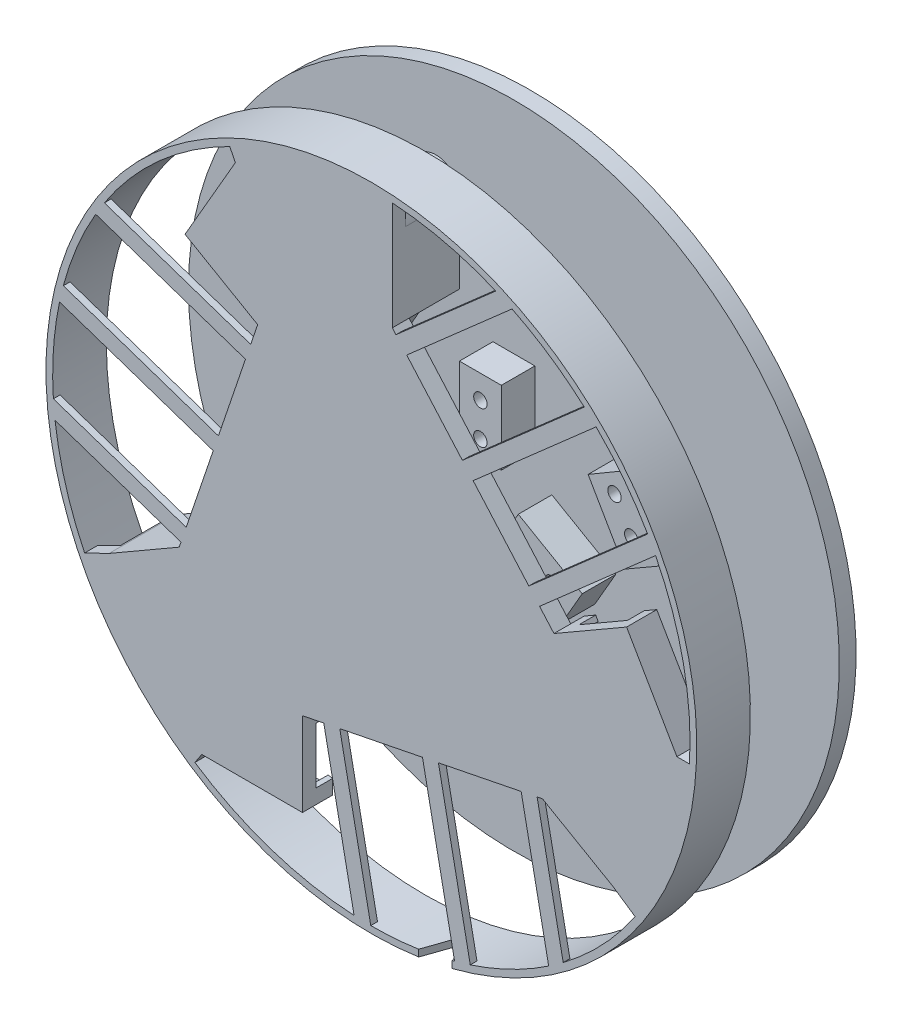
from build123d import *

# Parameters (mm, degrees)
CROQUIS1_R                  = 9.313545519
SALIENTE_EXTRUIR2_DEPTH     = 20
CROQUIS1_R_2                = 2
SALIENTE_EXTRUIR2_2_DEPTH   = 20
SALIENTE_EXTRUIR2_3_DEPTH   = 20
SALIENTE_EXTRUIR2_4_DEPTH   = 20
CROQUIS2_R                  = 97
SALIENTE_EXTRUIR3_DEPTH     = 4
CROQUIS3_R                  = 2
CORTAR_EXTRUIR2_DEPTH       = 36
SALIENTE_EXTRUIR6_DEPTH     = 5
CROQUIS6_R                  = 97
CROQUIS6_R_2                = 95
SALIENTE_EXTRUIR7_DEPTH     = 35
CROQUIS7_W                  = 36.537467555
CROQUIS7_H                  = 51.413436488
CORTAR_EXTRUIR6_DEPTH       = 40
SALIENTE_EXTRUIR13_DEPTH    = 3
CROQUIS12_W                 = 10
CROQUIS12_H                 = 16.770096614
CORTAR_EXTRUIR7_DEPTH       = 10
CORTAR_EXTRUIR7_TAPER       = 24
SALIENTE_EXTRUIR20_DEPTH    = 2
SALIENTE_EXTRUIR22_DEPTH    = 2
CROQUIS21_R                 = 2
SALIENTE_EXTRUIR23_DEPTH    = 12.5
CROQUIS26_R                 = 2
SALIENTE_EXTRUIR25_DEPTH    = 10
CROQUIS29_R                 = 97
SALIENTE_EXTRUIR26_DEPTH    = 5
CROQUIS32_R                 = 97
CROQUIS32_R_2               = 95
CORTAR_EXTRUIR9_DEPTH       = 23
SALIENTE_EXTRUIR28_DEPTH    = 1
CROQUIS38_W                 = 12.5
CROQUIS38_H                 = 24.157813479
CROQUIS38_H_2               = 22.825822027
CROQUIS38_H_3               = 74.173968243
CORTAR_EXTRUIR17_DEPTH      = 202
CORTAR_EXTRUIR17_DEPTH_BACK = 299


with BuildPart() as part:
    # Croquis1 → Saliente-Extruir2 (new body)
    with BuildSketch(Plane.XY):
        with Locations((-174.594182716, 121.255426097)):
            Circle(CROQUIS1_R)
    extrude(amount=SALIENTE_EXTRUIR2_DEPTH)

    # Croquis7 → Cortar-Extruir6 (cut, through all)
    with BuildSketch(Plane.XY.offset(20)):
        with Locations((-172.983924952, 117.945017294)):
            Rectangle(CROQUIS7_W, CROQUIS7_H)
    extrude(amount=-CORTAR_EXTRUIR6_DEPTH, mode=Mode.SUBTRACT)


with BuildPart() as body_2:
    # Croquis1 → Saliente-Extruir2 2 (new body)
    with BuildSketch(Plane.XY):
        with BuildLine():
            Line((-250.851688073, 84.445013217), (-252.79514461, 83.322958062))
            ThreePointArc((-252.79514461, 83.322958062), (-256.056625394, 75.449046919), (-249.29514461, 70.260780235))
            Line((-249.29514461, 70.260780235), (-247.137331132, 70.260780235))
            Line((-247.137331132, 70.260780235), (-225.137331132, 70.260780235))
            Line((-225.137331132, 70.260780235), (-225.137331132, 82.760780235))
            Line((-225.137331132, 82.760780235), (-228.768865169, 82.760780235))
            Line((-228.768865169, 82.760780235), (-225.623864438, 84.576547254))
            Line((-225.623864438, 84.576547254), (-231.873864438, 95.401864801))
            Line((-231.873864438, 95.401864801), (-244.676423321, 88.010303983))
            Line((-244.676423321, 88.010303983), (-250.851688073, 84.445013217))
        make_face()
        with Locations((-234.811042265, 86.489206027)):
            Circle(CROQUIS1_R_2, mode=Mode.SUBTRACT)
        with Locations((-243.471296302, 81.489206027)):
            Circle(CROQUIS1_R_2, mode=Mode.SUBTRACT)
        with Locations((-232.137331132, 76.510780235)):
            Circle(CROQUIS1_R_2, mode=Mode.SUBTRACT)
        with Locations((-242.137331132, 76.510780235)):
            Circle(CROQUIS1_R_2, mode=Mode.SUBTRACT)
    extrude(amount=SALIENTE_EXTRUIR2_2_DEPTH)



with BuildPart() as body_3:
    # Croquis1 → Saliente-Extruir2 3 (new body)
    with BuildSketch(Plane.XY):
        with BuildLine():
            Line((-180.844182716, 187.419400274), (-180.844182716, 183.787866237))
            Line((-180.844182716, 183.787866237), (-168.344182716, 183.787866237))
            Line((-168.344182716, 183.787866237), (-168.344182716, 198.570987873))
            Line((-168.344182716, 198.570987873), (-168.344182716, 205.701569406))
            Line((-168.344182716, 205.701569406), (-168.344182716, 207.945679716))
            ThreePointArc((-168.344182716, 207.945679716), (-173.5324494, 214.7071605), (-181.406360543, 211.445679716))
            Line((-181.406360543, 211.445679716), (-182.485267282, 209.576958427))
            Line((-182.485267282, 209.576958427), (-193.485267282, 190.524399544))
            Line((-193.485267282, 190.524399544), (-182.659949735, 184.274399544))
            Line((-182.659949735, 184.274399544), (-180.844182716, 187.419400274))
        make_face()
        with Locations((-179.572608508, 202.121831408)):
            Circle(CROQUIS1_R_2, mode=Mode.SUBTRACT)
        with Locations((-174.594182716, 190.787866237)):
            Circle(CROQUIS1_R_2, mode=Mode.SUBTRACT)
        with Locations((-184.572608508, 193.46157737)):
            Circle(CROQUIS1_R_2, mode=Mode.SUBTRACT)
        with Locations((-174.594182716, 200.787866237)):
            Circle(CROQUIS1_R_2, mode=Mode.SUBTRACT)
    extrude(amount=SALIENTE_EXTRUIR2_3_DEPTH)


with BuildPart() as body_4:
    # Croquis1 → Saliente-Extruir2 4 (new body)
    with BuildSketch(Plane.XY):
        with BuildLine():
            Line((-123.564500994, 84.576547254), (-110.761942111, 77.184986436))
            Line((-110.761942111, 77.184986436), (-104.586677359, 73.619695669))
            Line((-104.586677359, 73.619695669), (-102.643220822, 72.497640514))
            ThreePointArc((-102.643220822, 72.497640514), (-94.193473354, 73.610070873), (-93.081042995, 82.059818341))
            Line((-93.081042995, 82.059818341), (-94.159949735, 83.92853963))
            Line((-94.159949735, 83.92853963), (-105.159949735, 102.981098513))
            Line((-105.159949735, 102.981098513), (-115.985267282, 96.731098513))
            Line((-115.985267282, 96.731098513), (-114.169500263, 93.586097782))
            Line((-114.169500263, 93.586097782), (-117.314500994, 95.401864801))
            Line((-117.314500994, 95.401864801), (-123.564500994, 84.576547254))
        make_face()
        with Locations((-102.072608508, 85.133666649)):
            Circle(CROQUIS1_R_2, mode=Mode.SUBTRACT)
        with Locations((-107.072608508, 93.793920687)):
            Circle(CROQUIS1_R_2, mode=Mode.SUBTRACT)
        with Locations((-105.71706913, 81.489206027)):
            Circle(CROQUIS1_R_2, mode=Mode.SUBTRACT)
        with Locations((-114.377323168, 86.489206027)):
            Circle(CROQUIS1_R_2, mode=Mode.SUBTRACT)
    extrude(amount=SALIENTE_EXTRUIR2_4_DEPTH)


with BuildPart() as body_2_1:
    add(body_2.part)

    add(body_3.part)  # Saliente-Extruir3 merges body 3

    add(body_4.part)  # Saliente-Extruir3 merges body 4
    # Croquis2 → Saliente-Extruir3 (add)
    with BuildSketch(Plane.XY.offset(20)):
        with Locations((-174.594182716, 121.255426097)):
            Circle(CROQUIS2_R)
        with BuildLine():
            Line((-105.159949735, 102.981098513), (-120.159949735, 128.961860627))
            Line((-120.159949735, 128.961860627), (-98.50931464, 141.461860627))
            Line((-98.50931464, 141.461860627), (-83.50931464, 115.481098513))
            Line((-83.50931464, 115.481098513), (-79.769833834, 115.481098513))
            ThreePointArc((-79.769833834, 115.481098513), (-103.302441057, 184.044657429), (-168.344182716, 216.049611046))
            Line((-168.344182716, 216.049611046), (-168.344182716, 207.945679716))
            Line((-168.344182716, 207.945679716), (-168.344182716, 183.787866237))
            Line((-168.344182716, 183.787866237), (-180.844182716, 183.787866237))
            Line((-180.844182716, 183.787866237), (-180.844182716, 187.419400274))
            Line((-180.844182716, 187.419400274), (-182.659949735, 184.274399544))
            Line((-182.659949735, 184.274399544), (-193.485267282, 190.524399544))
            Line((-193.485267282, 190.524399544), (-208.485267282, 164.54363743))
            Line((-208.485267282, 164.54363743), (-230.135902377, 177.04363743))
            Line((-230.135902377, 177.04363743), (-217.348968797, 199.191256063))
            Line((-217.348968797, 199.191256063), (-215.135902377, 203.024399544))
            Line((-215.135902377, 203.024399544), (-216.793807303, 206.368243491))
            ThreePointArc((-216.793807303, 206.368243491), (-264.48542547, 151.989193784), (-260.069291522, 79.794531575))
            Line((-260.069291522, 79.794531575), (-252.79514461, 83.322958062))
            Line((-252.79514461, 83.322958062), (-249.29514461, 70.260780235))
            Line((-249.29514461, 70.260780235), (-225.137331132, 70.260780235))
            Line((-225.137331132, 70.260780235), (-195.137331132, 70.260780235))
            Line((-195.137331132, 70.260780235), (-195.137331132, 45.260780235))
            Line((-195.137331132, 45.260780235), (-225.137331132, 45.260780235))
            Line((-225.137331132, 45.260780235), (-227.204232473, 42.153070478))
            ThreePointArc((-227.204232473, 42.153070478), (-156.26478491, 28.040442452), (-95.950440393, 67.962257741))
            Line((-95.950440393, 67.962257741), (-102.643220822, 72.497640514))
            Line((-102.643220822, 72.497640514), (-94.499038829, 84.515859169))
            Line((-94.499038829, 84.515859169), (-105.159949735, 102.981098513))
        make_face(mode=Mode.SUBTRACT)
    extrude(amount=-SALIENTE_EXTRUIR3_DEPTH)

    # Croquis3 → Cortar-Extruir2 (cut)
    with BuildSketch(Plane(origin=(0, 0, 0), x_dir=(-1, 0, 0), z_dir=(0, 0, -1))):
        with Locations((174.594182716, 200.787866237)):
            Circle(CROQUIS3_R)
        with Locations((179.572608508, 202.121831408)):
            Circle(CROQUIS3_R)
        with Locations((184.572608508, 193.46157737)):
            Circle(CROQUIS3_R)
        with Locations((174.594182716, 190.787866237)):
            Circle(CROQUIS3_R)
    extrude(amount=-CORTAR_EXTRUIR2_DEPTH, mode=Mode.SUBTRACT)

    # Croquis5 → Saliente-Extruir6 (add)
    with BuildSketch(Plane(origin=(0, 0, 16), x_dir=(-1, 0, 0), z_dir=(0, 0, -1))):
        Polygon((195.137331132, 70.260780235), (195.137331132, 66.284420348), (196.629622791, 66.284420348), (196.629622791, 68.733603213), (241.76303174, 68.733603213), (241.76303174, 70.260780235), (225.137331132, 70.260780235), align=None)
        Polygon((120.159949735, 128.961860627), (116.716321058, 130.95004057), (115.970175228, 129.657678083), (118.091229808, 128.433086651), (95.524525333, 89.346407942), (96.847099431, 88.582819431), (105.159949735, 102.981098513), align=None)
        Polygon((208.485267282, 164.54363743), (211.928895959, 166.531817374), (211.182750129, 167.824179861), (209.06169555, 166.599588428), (186.494991075, 205.686267137), (185.172416978, 204.922678626), (193.485267282, 190.524399544), align=None)
        Polygon((230.135902377, 177.04363743), (215.135902377, 203.024399544), (213.023103549, 202.793743883), (226.723342516, 179.013879784), (227.75030659, 177.231351308), (225.551355532, 175.964474641), (226.394943709, 174.883793937), align=None)
        Polygon((198.549890992, 47.231022589), (225.993976884, 47.205845524), (225.137331132, 45.260780235), (195.137331132, 45.260780235), (195.137331132, 49.580467222), (196.495022164, 49.770695662), (196.492694012, 47.232909851), align=None)
        Polygon((83.50931464, 115.481098513), (98.50931464, 141.461860627), (102.250273307, 139.302017133), (101.736170452, 138.031107989), (99.539547547, 139.302017133), (98.50931464, 137.521375919), (84.765467716, 113.766688886), align=None)
    extrude(amount=SALIENTE_EXTRUIR6_DEPTH)

    # Croquis6 → Saliente-Extruir7 (add)
    with BuildSketch(Plane(origin=(0, 0, 16), x_dir=(-1, 0, 0), z_dir=(0, 0, -1))):
        with Locations((174.594182716, 121.255426097)):
            Circle(CROQUIS6_R)
        with Locations((174.594182716, 121.255426097)):
            Circle(CROQUIS6_R_2, mode=Mode.SUBTRACT)
    extrude(amount=SALIENTE_EXTRUIR7_DEPTH)

    # Croquis9 → Saliente-Extruir13 (add)
    with BuildSketch(Plane.XY.offset(20)):
        Polygon((-195.137331132, 70.260780235), (-123.564500994, 84.576547254), (-117.314500994, 95.401864801), (-114.169500263, 93.586097782), (-115.985267282, 96.731098513), (-105.159949735, 102.981098513), (-120.159949735, 128.961860627), (-168.344182716, 183.787866237), (-180.844182716, 183.787866237), (-180.844182716, 187.419400274), (-182.659949735, 184.274399544), (-193.485267282, 190.524399544), (-208.485267282, 164.54363743), (-231.873864438, 95.401864801), (-225.623864438, 84.576547254), (-228.768865169, 82.760780235), (-225.137331132, 82.760780235), (-225.137331132, 70.260780235), align=None)
    extrude(amount=-SALIENTE_EXTRUIR13_DEPTH)

    # Croquis12 → Cortar-Extruir7 (cut)
    with BuildSketch(Plane.XY.offset(20)):
        with Locations((-155.482716106, 26.156783394)):
            Rectangle(CROQUIS12_W, CROQUIS12_H)
    extrude(amount=-CORTAR_EXTRUIR7_DEPTH, taper=CORTAR_EXTRUIR7_TAPER, mode=Mode.SUBTRACT)

    # Croquis13 → Saliente-Extruir20 (add)
    with BuildSketch(Plane.XY.offset(20)):
        with BuildLine():
            Line((-256.780786671, 168.903743281), (-212.120681578, 153.796563247))
            Line((-212.120681578, 153.796563247), (-210.566560891, 158.390881516))
            Line((-210.566560891, 158.390881516), (-254.173169225, 173.141695053))
            ThreePointArc((-254.173169225, 173.141695053), (-255.504729762, 171.039794896), (-256.780786671, 168.903743281))
        make_face()
        with BuildLine():
            Line((-267.546087574, 140.875400188), (-221.733686547, 125.378432847))
            Line((-221.733686547, 125.378432847), (-220.17956586, 129.972751116))
            Line((-220.17956586, 129.972751116), (-266.418272853, 145.613925036))
            ThreePointArc((-266.418272853, 145.613925036), (-267.012554732, 143.251892041), (-267.546087574, 140.875400188))
        make_face()
        with BuildLine():
            Line((-231.346691517, 96.960302446), (-229.792570829, 101.554620715))
            Line((-229.792570829, 101.554620715), (-269.38452378, 114.947396211))
            ThreePointArc((-269.38452378, 114.947396211), (-269.171057581, 112.299157855), (-268.883619856, 109.657924477))
            Line((-268.883619856, 109.657924477), (-231.346691517, 96.960302446))
        make_face()
        with BuildLine():
            Line((-111.126834303, 191.944149989), (-147.453802216, 160.017930562))
            Line((-147.453802216, 160.017930562), (-144.252066225, 156.374863432))
            Line((-144.252066225, 156.374863432), (-107.587058769, 188.598171366))
            ThreePointArc((-107.587058769, 188.598171366), (-109.335498408, 190.293851067), (-111.126834303, 191.944149989))
        make_face()
        with BuildLine():
            Line((-167.258122586, 182.552102273), (-164.056386596, 178.909035142))
            Line((-164.056386596, 178.909035142), (-132.661926314, 206.500284435))
            ThreePointArc((-132.661926314, 206.500284435), (-135.062101104, 207.639536462), (-137.49319517, 208.711224779))
            Line((-137.49319517, 208.711224779), (-167.258122586, 182.552102273))
        make_face()
        with BuildLine():
            Line((-92.23622761, 168.606954381), (-127.649481846, 137.483758852))
            Line((-127.649481846, 137.483758852), (-124.447745855, 133.840691722))
            Line((-124.447745855, 133.840691722), (-89.869862438, 164.229715544))
            ThreePointArc((-89.869862438, 164.229715544), (-91.024381102, 166.433830874), (-92.23622761, 168.606954381))
        make_face()
        with BuildLine():
            Line((-145.109626271, 30.946728115), (-154.595059385, 78.369914883))
            Line((-154.595059385, 78.369914883), (-159.350916063, 77.418663744))
            Line((-159.350916063, 77.418663744), (-149.777216527, 29.55418189))
            ThreePointArc((-149.777216527, 29.55418189), (-147.434495009, 30.220535184), (-145.109626271, 30.946728115))
        make_face()
        with BuildLine():
            Line((-174.765533867, 26.25558063), (-184.012384725, 72.485956193))
            Line((-184.012384725, 72.485956193), (-188.768241403, 71.534705054))
            Line((-188.768241403, 71.534705054), (-179.739516485, 26.394867695))
            ThreePointArc((-179.739516485, 26.394867695), (-177.253437284, 26.292652522), (-174.765533867, 26.25558063))
        make_face()
        with BuildLine():
            Line((-125.177734046, 84.253873573), (-129.933590723, 83.302622435))
            Line((-129.933590723, 83.302622435), (-121.736098055, 42.318597646))
            ThreePointArc((-121.736098055, 42.318597646), (-119.549389463, 43.827583975), (-117.405733123, 45.397129036))
            Line((-117.405733123, 45.397129036), (-125.177734046, 84.253873573))
        make_face()
    extrude(amount=-SALIENTE_EXTRUIR20_DEPTH)

    # Croquis14 → Saliente-Extruir22 (add)
    with BuildSketch(Plane(origin=(0, 0, 17), x_dir=(-1, 0, 0), z_dir=(0, 0, -1))):
        Polygon((193.485267282, 190.524399544), (182.659949735, 184.274399544), (180.844182716, 187.419400274), (180.844182716, 183.787866237), (168.344182716, 183.787866237), (120.159949735, 128.961860627), (105.159949735, 102.981098513), (115.985267282, 96.731098513), (114.169500263, 93.586097782), (117.314500994, 95.401864801), (123.564500994, 84.576547254), (195.137331132, 70.260780235), (225.137331132, 70.260780235), (225.137331132, 82.760780235), (228.768865169, 82.760780235), (225.623864438, 84.576547254), (231.873864438, 95.401864801), (208.485267282, 164.54363743), align=None)
        Polygon((192.540713054, 187.060950871), (182.256661384, 181.123450871), (180.531682716, 180.66124423), (168.656682716, 180.66124423), (122.881661384, 128.5765389), (108.631661384, 103.894814892), (118.915713054, 97.957314892), (120.17848508, 96.694542866), (126.11598508, 86.410491196), (194.110173711, 72.810512528), (222.610173711, 72.810512528), (222.610173711, 84.685512528), (223.072380352, 86.410491196), (229.009880352, 96.694542866), (206.790713054, 162.379226864), align=None, mode=Mode.SUBTRACT)
    extrude(amount=SALIENTE_EXTRUIR22_DEPTH)

    # Croquis21 → Saliente-Extruir23 (add)
    with BuildSketch(Plane(origin=(0, 0, 0), x_dir=(-1, 0, 0), z_dir=(0, 0, -1))):
        Polygon((140.975036656, 143.502376972), (142.485267282, 142.630444914), (115.985267282, 96.731098513), (105.159949735, 102.981098513), (131.659949735, 148.880444914), align=None)
        Polygon((117.314500994, 95.401864801), (163.213847395, 121.901864801), (169.463847395, 111.076547254), (123.564500994, 84.576547254), align=None)
        with BuildLine():
            Line((249.29514461, 70.260780235), (225.137331132, 70.260780235))
            Line((225.137331132, 70.260780235), (172.137331132, 70.260780235))
            Line((172.137331132, 70.260780235), (172.137331132, 81.016916119))
            Line((172.137331132, 81.016916119), (172.137331132, 82.760780235))
            Line((172.137331132, 82.760780235), (225.137331132, 82.760780235))
            Line((225.137331132, 82.760780235), (228.768865169, 82.760780235))
            Line((228.768865169, 82.760780235), (225.623864438, 84.576547254))
            Line((225.623864438, 84.576547254), (179.724518038, 111.076547254))
            Line((179.724518038, 111.076547254), (185.974518038, 121.901864801))
            Line((185.974518038, 121.901864801), (231.873864438, 95.401864801))
            Line((231.873864438, 95.401864801), (252.79514461, 83.322958062))
            ThreePointArc((252.79514461, 83.322958062), (256.056625394, 75.449046919), (249.29514461, 70.260780235))
        make_face()
        with BuildLine():
            Line((181.406360543, 211.445679716), (193.485267282, 190.524399544))
            Line((193.485267282, 190.524399544), (219.985267282, 144.625053143))
            Line((219.985267282, 144.625053143), (210.67018036, 139.246985201))
            Line((210.67018036, 139.246985201), (209.159949735, 138.375053143))
            Line((209.159949735, 138.375053143), (182.659949735, 184.274399544))
            Line((182.659949735, 184.274399544), (180.844182716, 187.419400274))
            Line((180.844182716, 187.419400274), (180.844182716, 183.787866237))
            Line((180.844182716, 183.787866237), (180.844182716, 130.787866237))
            Line((180.844182716, 130.787866237), (168.344182716, 130.787866237))
            Line((168.344182716, 130.787866237), (168.344182716, 183.787866237))
            Line((168.344182716, 183.787866237), (168.344182716, 207.945679716))
            ThreePointArc((168.344182716, 207.945679716), (173.5324494, 214.7071605), (181.406360543, 211.445679716))
        make_face()
        with BuildLine():
            Line((115.985267282, 96.731098513), (105.159949735, 102.981098513))
            Line((105.159949735, 102.981098513), (93.081042995, 82.059818341))
            ThreePointArc((93.081042995, 82.059818341), (94.193473354, 73.610070873), (102.643220822, 72.497640514))
            Line((102.643220822, 72.497640514), (123.564500994, 84.576547254))
            Line((123.564500994, 84.576547254), (117.314500994, 95.401864801))
            Line((117.314500994, 95.401864801), (114.169500263, 93.586097782))
            Line((114.169500263, 93.586097782), (115.985267282, 96.731098513))
        make_face()
        with Locations((114.377323168, 86.489206027)):
            Circle(CROQUIS21_R, mode=Mode.SUBTRACT)
        with Locations((107.072608508, 93.793920687)):
            Circle(CROQUIS21_R, mode=Mode.SUBTRACT)
        with Locations((105.71706913, 81.489206027)):
            Circle(CROQUIS21_R, mode=Mode.SUBTRACT)
        with Locations((102.072608508, 85.133666649)):
            Circle(CROQUIS21_R, mode=Mode.SUBTRACT)
    extrude(amount=SALIENTE_EXTRUIR23_DEPTH)

    # Croquis26 → Saliente-Extruir25 (add)
    with BuildSketch(Plane(origin=(0, 0, -12.5), x_dir=(-1, 0, 0), z_dir=(0, 0, -1))):
        Polygon((210.844182716, 160.457876047), (209.028415698, 163.602876778), (198.20309815, 157.352876778), (205.594658968, 144.550317895), (209.159949735, 138.375053143), (220.028415698, 144.550317895), align=None)
        with Locations((207.115756924, 154.415698952)):
            Circle(CROQUIS26_R, mode=Mode.SUBTRACT)
        with Locations((212.115756924, 145.755444914)):
            Circle(CROQUIS26_R, mode=Mode.SUBTRACT)
        Polygon((168.344182716, 137.918447771), (168.344182716, 130.787866237), (180.844182716, 130.701569406), (180.844182716, 149.070035369), (180.844182716, 152.701569406), (168.344182716, 152.701569406), align=None)
        with Locations((174.594182716, 135.701569406)):
            Circle(CROQUIS26_R, mode=Mode.SUBTRACT)
        with Locations((174.594182716, 145.701569406)):
            Circle(CROQUIS26_R, mode=Mode.SUBTRACT)
        Polygon((190.419500263, 70.260780235), (194.0510343, 70.260780235), (194.0510343, 82.760780235), (179.267912665, 82.760780235), (172.137331132, 82.760780235), (172.0510343, 70.260780235), align=None)
        with Locations((187.0510343, 76.510780235)):
            Circle(CROQUIS26_R, mode=Mode.SUBTRACT)
        with Locations((177.0510343, 76.510780235)):
            Circle(CROQUIS26_R, mode=Mode.SUBTRACT)
        Polygon((192.149782789, 118.336574034), (185.974518038, 121.901864801), (179.649782789, 111.119695669), (195.557340942, 101.935462688), (198.702341672, 100.119695669), (204.952341672, 110.945013217), align=None)
        with Locations((187.104909808, 114.032354443)):
            Circle(CROQUIS26_R, mode=Mode.SUBTRACT)
        with Locations((195.765163846, 109.032354443)):
            Circle(CROQUIS26_R, mode=Mode.SUBTRACT)
        Polygon((122.518865169, 133.04762201), (120.70309815, 129.902621279), (131.528415698, 123.652621279), (138.919976515, 136.455180162), (142.485267282, 142.630444914), (131.70309815, 148.955180162), align=None)
        with Locations((129.615756924, 132.839799105)):
            Circle(CROQUIS26_R, mode=Mode.SUBTRACT)
        with Locations((134.615756924, 141.500053143)):
            Circle(CROQUIS26_R, mode=Mode.SUBTRACT)
        Polygon((163.288582643, 107.511256487), (169.463847395, 111.076547254), (163.288582643, 121.945013217), (147.381024491, 112.760780235), (144.23602376, 110.945013217), (150.48602376, 100.119695669), align=None)
        with Locations((162.083455624, 114.032354443)):
            Circle(CROQUIS26_R, mode=Mode.SUBTRACT)
        with Locations((153.423201586, 109.032354443)):
            Circle(CROQUIS26_R, mode=Mode.SUBTRACT)
    extrude(amount=SALIENTE_EXTRUIR25_DEPTH)

    # Croquis29 → Saliente-Extruir26 (add)
    with BuildSketch(Plane(origin=(0, 0, -22.5), x_dir=(-1, 0, 0), z_dir=(0, 0, -1))):
        with Locations((174.594182716, 121.255426097)):
            Circle(CROQUIS29_R)
    extrude(amount=SALIENTE_EXTRUIR26_DEPTH)

    # Croquis32 → Cortar-Extruir9 (cut)
    with BuildSketch(Plane(origin=(0, 0, -19), x_dir=(-1, 0, 0), z_dir=(0, 0, -1))):
        with Locations((174.594182716, 121.255426097)):
            Circle(CROQUIS32_R)
        with Locations((174.594182716, 121.255426097)):
            Circle(CROQUIS32_R_2, mode=Mode.SUBTRACT)
    extrude(amount=-CORTAR_EXTRUIR9_DEPTH, mode=Mode.SUBTRACT)

    # Croquis4 → Saliente-Extruir28 (add)
    with BuildSketch(Plane.XY.offset(20)):
        with BuildLine():
            Line((-110.745973806, 83.052157612), (-110.716478632, 81.412364453))
            ThreePointArc((-110.716478632, 81.412364453), (-106.287200278, 76.52181733), (-100.865073697, 80.281671216))
            ThreePointArc((-100.865073697, 80.281671216), (-97.154363713, 86.034148817), (-102.662484, 90.098749418))
            Line((-102.662484, 90.098749418), (-103.214358064, 90.613684295))
            ThreePointArc((-103.214358064, 90.613684295), (-109.224399032, 98.307211896), (-107.030871231, 88.79409489))
            Line((-107.030871231, 88.79409489), (-109.40316432, 86.99689073))
            ThreePointArc((-109.40316432, 86.99689073), (-119.11060139, 88.100440731), (-110.745973806, 83.052157612))
        make_face()
        with BuildLine():
            Line((-173.433286155, 195.651231243), (-172.02793121, 196.496671391))
            ThreePointArc((-172.02793121, 196.496671391), (-170.007232339, 202.777812528), (-175.97442461, 205.593584947))
            ThreePointArc((-175.97442461, 205.593584947), (-182.811571339, 205.930915258), (-183.577558572, 199.128442863))
            Line((-183.577558572, 199.128442863), (-183.747568225, 198.393038465))
            ThreePointArc((-183.747568225, 198.393038465), (-187.405338089, 189.341426508), (-180.263500992, 195.997635811))
            Line((-180.263500992, 195.997635811), (-177.52092999, 194.841771811))
            ThreePointArc((-177.52092999, 194.841771811), (-173.622913789, 185.883109702), (-173.433286155, 195.651231243))
        make_face()
        with BuildLine():
            Line((-239.603288188, 85.062889438), (-241.038138306, 85.857242447))
            ThreePointArc((-241.038138306, 85.857242447), (-247.488115531, 84.466648434), (-246.943049841, 77.891022129))
            ThreePointArc((-246.943049841, 77.891022129), (-243.816613096, 71.801214216), (-237.542505576, 74.539086012))
            Line((-237.542505576, 74.539086012), (-236.820621859, 74.759555532))
            ThreePointArc((-236.820621859, 74.759555532), (-227.152811028, 76.117639888), (-236.488175925, 78.974547592))
            Line((-236.488175925, 78.974547592), (-236.858453839, 81.927615751))
            ThreePointArc((-236.858453839, 81.927615751), (-231.049032969, 89.782727859), (-239.603288188, 85.062889438))
        make_face()
    extrude(amount=-SALIENTE_EXTRUIR28_DEPTH)

    # Croquis38 → Cortar-Extruir17 (cut, two sides)
    with BuildSketch(Plane(origin=(-168.344182716, 0, 0), x_dir=(0, 0, -1), z_dir=(1, 0, 0))) as cortar_extruir17_sk:
        Polygon((12.5, 183.787866237), (0, 183.787866237), (0, 130.787866237), (12.5, 130.787866237), (12.5, 152.701569406), align=None)
        with Locations((6.25, 195.866772976)):
            Rectangle(CROQUIS38_W, CROQUIS38_H)
        with Locations((6.25, 219.35859073)):
            Rectangle(CROQUIS38_W, CROQUIS38_H_2)
        with Locations((6.25, 93.700882116)):
            Rectangle(CROQUIS38_W, CROQUIS38_H_3)
    extrude(amount=CORTAR_EXTRUIR17_DEPTH, mode=Mode.SUBTRACT)
    extrude(cortar_extruir17_sk.sketch, amount=-CORTAR_EXTRUIR17_DEPTH_BACK, mode=Mode.SUBTRACT)


solid = body_2_1.part
